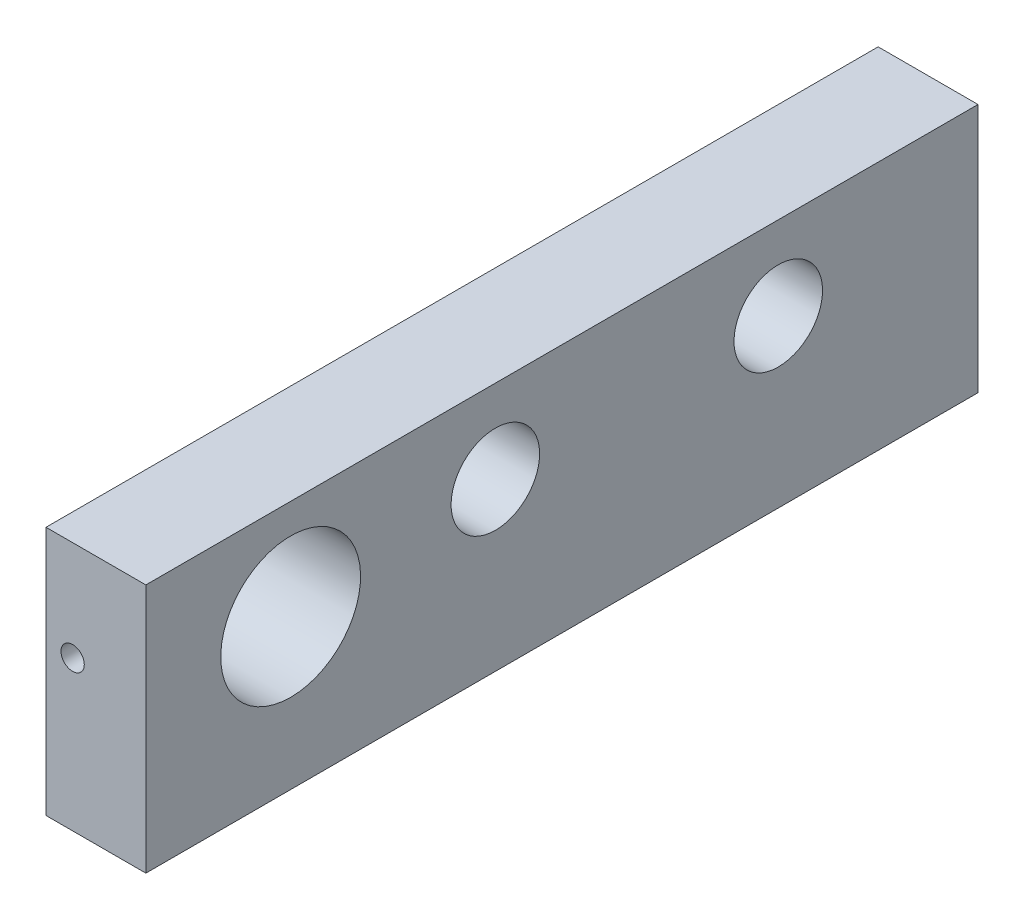
from build123d import *

# Parameters (mm, degrees)
SKETCH1_W           = 7.62
SKETCH1_H           = 19.05
BOSS_EXTRUDE1_DEPTH = 63.5
SKETCH2_R           = 0.889
CUT_EXTRUDE1_DEPTH  = 6.35
SKETCH3_R           = 3.3782
CUT_EXTRUDE2_DEPTH  = 8.62
SKETCH4_R           = 3.3782
CUT_EXTRUDE3_DEPTH  = 8.62
SKETCH5_R           = 5.334
CUT_EXTRUDE4_DEPTH  = 8.62


with BuildPart() as part:
    # Sketch1 → Boss-Extrude1 (new body)
    with BuildSketch(Plane.XY):
        with Locations((3.81, 9.525)):
            Rectangle(SKETCH1_W, SKETCH1_H)
    extrude(amount=-BOSS_EXTRUDE1_DEPTH)

    # Sketch2 → Cut-Extrude1 (cut)
    with BuildSketch(Plane.XY):
        with Locations((2.032, 11.43)):
            Circle(SKETCH2_R)
    extrude(amount=-CUT_EXTRUDE1_DEPTH, mode=Mode.SUBTRACT)

    # Sketch3 → Cut-Extrude2 (cut, through all)
    with BuildSketch(Plane.ZY):
        with Locations((-48.26, 12.7)):
            Circle(SKETCH3_R)
    extrude(amount=-CUT_EXTRUDE2_DEPTH, mode=Mode.SUBTRACT)

    # Sketch4 → Cut-Extrude3 (cut, through all)
    with BuildSketch(Plane.ZY):
        with Locations((-26.67, 12.7)):
            Circle(SKETCH4_R)
    extrude(amount=-CUT_EXTRUDE3_DEPTH, mode=Mode.SUBTRACT)

    # Sketch5 → Cut-Extrude4 (cut, through all)
    with BuildSketch(Plane.ZY):
        with Locations((-11.049, 11.43)):
            Circle(SKETCH5_R)
    extrude(amount=-CUT_EXTRUDE4_DEPTH, mode=Mode.SUBTRACT)


solid = part.part
